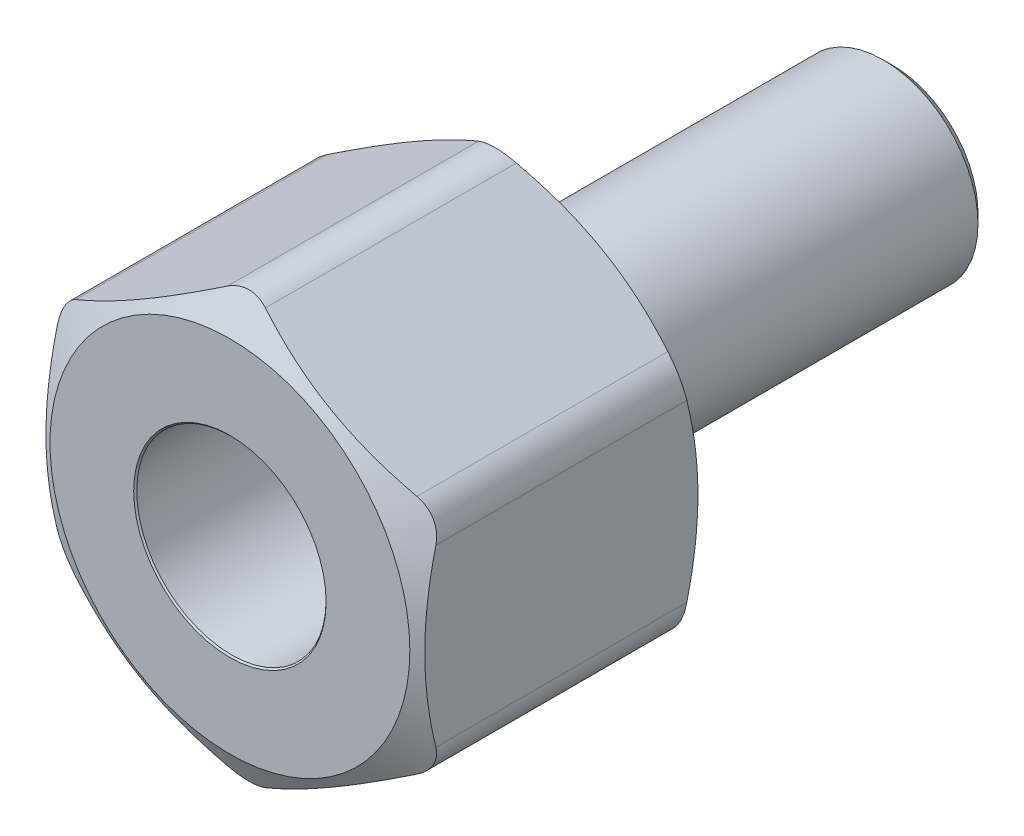
from build123d import *

# Parameters (mm, degrees)
SKETCH4_R           = 4.7625
BOSS_EXTRUDE1_DEPTH = 9.525
SKETCH5_OUTSIDE_W   = 108.066
SKETCH5_OUTSIDE_H   = 110.03
SKETCH5_OUTSIDE_R   = 6.0325
CUT_EXTRUDE1_DEPTH  = 25.249463052
CUT_EXTRUDE1_DRAFT  = -60
SKETCH6_OUTSIDE_W   = 79.422
SKETCH6_OUTSIDE_H   = 81.386
SKETCH6_OUTSIDE_R   = 6.0325
CUT_EXTRUDE2_DEPTH  = 16.980482888
CUT_EXTRUDE2_DRAFT  = -60
FILLET1_R           = 1.27
SKETCH9_R           = 3.4925
BOSS_EXTRUDE2_DEPTH = 4.7752
SKETCH10_W          = 4.7752
SKETCH10_H          = 3.175


with BuildPart() as part:
    # Sketch3 → Revolve1 (revolve)
    with BuildSketch(Plane(origin=(0, 0, 0), x_dir=(0, 0, -1), z_dir=(1, 0, 0))):
        with BuildLine():
            Line((-4.7498, 2.8575), (-4.7498, 0))
            Line((-4.7498, 0), (12.7, 0))
            Line((12.7, 0), (12.7, 2.8575))
            Line((12.7, 2.8575), (12.3825, 3.175))
            Line((12.3825, 3.175), (2.00025, 3.175))
            Line((2.00025, 3.175), (1.524, 2.350110803))
            Line((1.524, 2.350110803), (0.3175, 2.350110803))
            ThreePointArc((0.3175, 2.350110803), (0.092993597, 2.4431044), (0, 2.667610803))
            Line((0, 2.667610803), (0, 6.35))
            Line((0, 6.35), (-9.525, 6.35))
            Line((-9.525, 6.35), (-9.525, 3.4925))
            Line((-9.525, 3.4925), (-9.2075, 3.175))
            Line((-9.2075, 3.175), (-5.0673, 3.175))
            Line((-5.0673, 3.175), (-4.7498, 2.8575))
        make_face()
    revolve(axis=Axis((0, 0, -12.7), (0, 0, 1)))

    # Sketch4 → Boss-Extrude1 (add)
    with BuildSketch(Plane.XY.offset(9.525)):
        Polygon((-6.35, 3.666174209), (-6.35, -3.666174209), (0, -7.332348419), (6.35, -3.666174209), (6.35, 3.666174209), (0, 7.332348419), align=None)
        Circle(SKETCH4_R, mode=Mode.SUBTRACT)
    extrude(amount=-BOSS_EXTRUDE1_DEPTH)


with BuildPart() as cut_extrude1_tool:
    # Sketch5 outside → Cut-Extrude1 (with draft: the straight prism first)
    with BuildSketch(Plane.XY.offset(9.525)):
        Rectangle(SKETCH5_OUTSIDE_W, SKETCH5_OUTSIDE_H)
        Circle(SKETCH5_OUTSIDE_R, mode=Mode.SUBTRACT)
    extrude(amount=-CUT_EXTRUDE1_DEPTH)
    # Cut-Extrude1: the draft: its side faces are tilted about the plane it starts from
    cut_extrude1_sides = [cut_extrude1_tool.faces().sort_by_distance(p)[0] for p in [
        (0, -55.015, -3.099731526),
        (54.033, 0, -3.099731526),
        (0, 55.015, -3.099731526),
        (-54.033, 0, -3.099731526),
        (-6.0325, 0, -3.099731526),
    ]]
    draft(cut_extrude1_sides, Plane.XY.offset(9.525), CUT_EXTRUDE1_DRAFT)


with BuildPart() as part_1:
    add(part.part)

    # Cut-Extrude1: cut by cut_extrude1_tool
    add(cut_extrude1_tool.part, mode=Mode.SUBTRACT)


with BuildPart() as cut_extrude2_tool:
    # Sketch6 outside → Cut-Extrude2 (with draft: the straight prism first)
    with BuildSketch(Plane(origin=(0, 0, 0), x_dir=(-1, 0, 0), z_dir=(0, 0, -1))):
        Rectangle(SKETCH6_OUTSIDE_W, SKETCH6_OUTSIDE_H)
        Circle(SKETCH6_OUTSIDE_R, mode=Mode.SUBTRACT)
    extrude(amount=-CUT_EXTRUDE2_DEPTH)
    # Cut-Extrude2: the draft: its side faces are tilted about the plane it starts from
    cut_extrude2_sides = [cut_extrude2_tool.faces().sort_by_distance(p)[0] for p in [
        (0, -40.693, 8.490241444),
        (-39.711, 0, 8.490241444),
        (0, 40.693, 8.490241444),
        (39.711, 0, 8.490241444),
        (6.0325, 0, 8.490241444),
    ]]
    draft(cut_extrude2_sides, Plane(origin=(0, 0, 0), x_dir=(-1, 0, 0), z_dir=(0, 0, -1)), CUT_EXTRUDE2_DRAFT)


with BuildPart() as part_2:
    add(part_1.part)

    # Cut-Extrude2: cut by cut_extrude2_tool
    add(cut_extrude2_tool.part, mode=Mode.SUBTRACT)

    # Fillet1
    fillet1_edges = [part_2.edges().sort_by_distance(p)[0] for p in [
        (0, 7.332348419, 4.7625),
        (-6.35, -3.666174209, 4.7625),
        (0, -7.332348419, 4.7625),
        (6.35, -3.666174209, 4.7625),
        (6.35, 3.666174209, 4.7625),
        (-6.35, 3.666174209, 4.7625),
    ]]
    fillet(fillet1_edges, radius=FILLET1_R)

    # Sketch9 → Boss-Extrude2 (add)
    with BuildSketch(Plane.XY.offset(4.7498)):
        Circle(SKETCH9_R)
    extrude(amount=BOSS_EXTRUDE2_DEPTH)


with BuildPart() as body_2:
    # Sketch10 → Revolve2 (revolve)
    with BuildSketch(Plane(origin=(0, 0, 0), x_dir=(0, 0, -1), z_dir=(1, 0, 0))):
        with Locations((-7.1374, 1.5875)):
            Rectangle(SKETCH10_W, SKETCH10_H)
    revolve(axis=Axis((0, 0, -12.7), (0, 0, 1)))


with BuildPart() as part_3:
    add(part_2.part)

    # Combine1: cut body 2
    add(body_2.part, mode=Mode.SUBTRACT)

    # Cut-Extrude3 cone 1 section (through the dimple's axis) → Cut-Extrude3 (revolve, cut)
    with BuildSketch(Plane(origin=(0, 0, 9.525), x_dir=(0, -1, 0), z_dir=(1, 0, 0))):
        Polygon((0, 0), (3.2258, 0), (0, 3.2258), align=None)
    revolve(axis=Axis((0, 0, 9.525), (0, 0, -1)), mode=Mode.SUBTRACT)


solid = part_3.part
